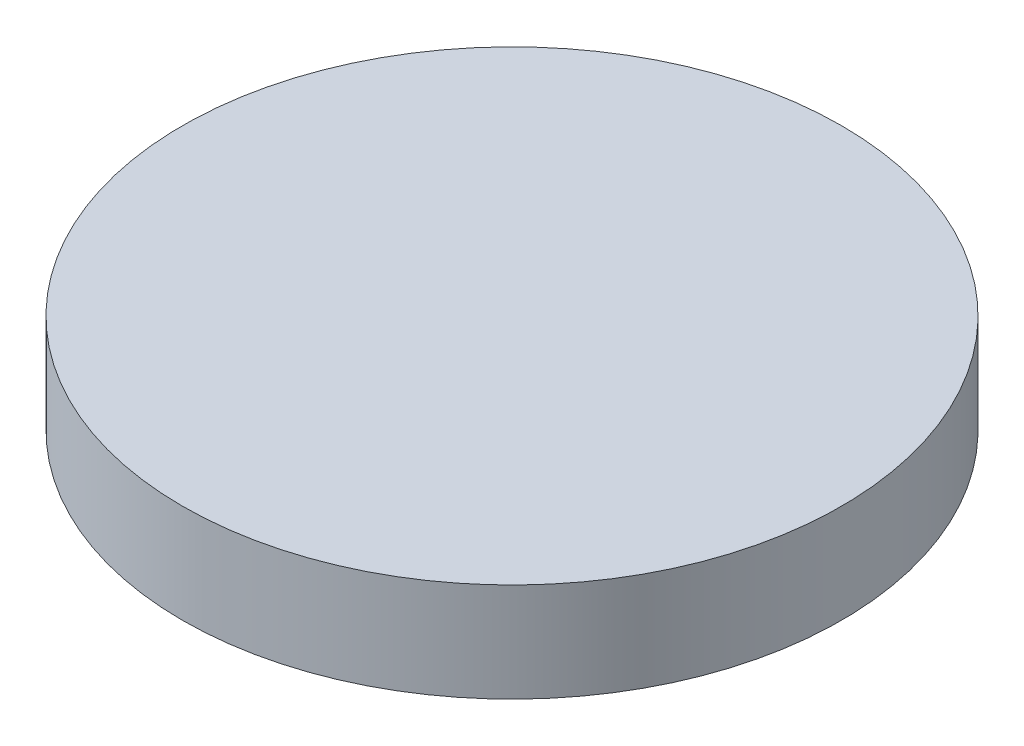
from build123d import *

# Parameters (mm, degrees)
SKETCH_1_R      = 127
EXTRUDE_1_DEPTH = 38.1


with BuildPart() as part:
    # 草图1 → 凸台-拉伸1 (new body)
    with BuildSketch(Plane(origin=(0, 0, 0), x_dir=(1, 0, 0), z_dir=(0, 1, 0))):
        with Locations(Location((0, 0, 0), (0, 0, 270))):  # turned: the seam where the file's is
            Circle(SKETCH_1_R)
    extrude(amount=EXTRUDE_1_DEPTH)


solid = part.part
